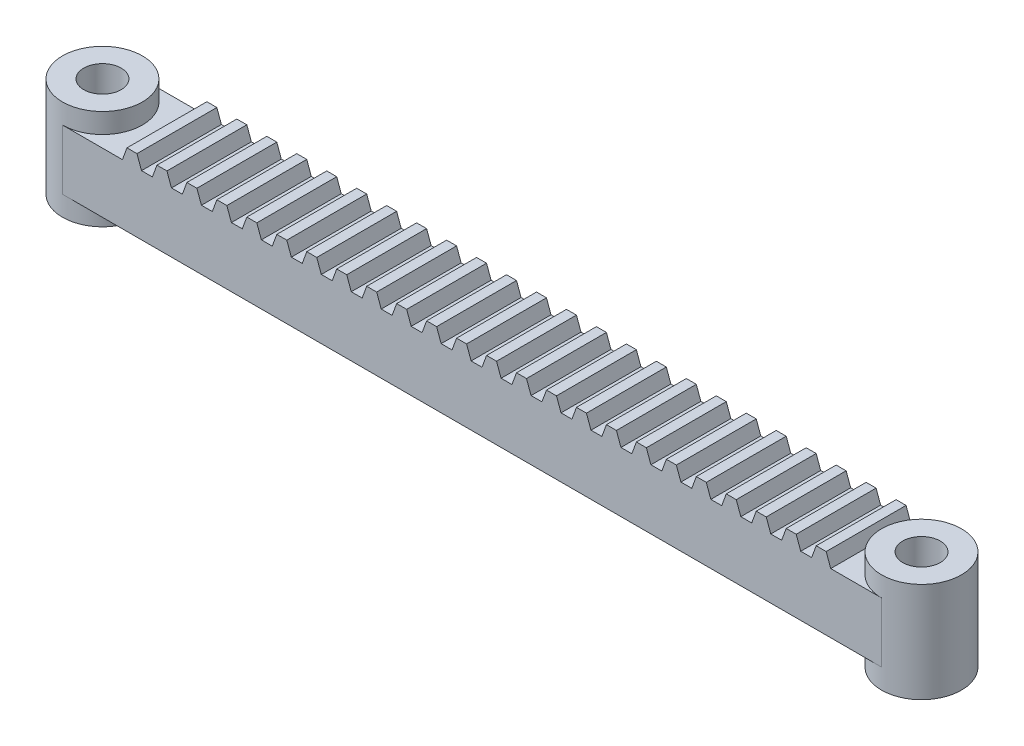
from build123d import *

# Parameters (mm, degrees)
BOSS_EXTRUDE1_DEPTH = 6
SKETCH1_3_R         = 8
SKETCH1_3_R_2       = 3.75
BOSS_EXTRUDE2_DEPTH = 10
BOSS_EXTRUDE3_DEPTH = 16


with BuildPart() as part:
    # Sketch1 → Boss-Extrude1 (new, symmetric)
    with BuildSketch(Plane(origin=(0, 0, 0), x_dir=(1, 0, 0), z_dir=(0, 1, 0))):
        with BuildLine():
            Line((82, 8), (-82, 8))
            ThreePointArc((-82, 8), (-76.343145751, 5.656854249), (-74, 0))
            ThreePointArc((-74, 0), (-76.343145751, -5.656854249), (-82, -8))
            Line((-82, -8), (82, -8))
            ThreePointArc((82, -8), (74, 0), (82, 8))
        make_face()
    extrude(amount=BOSS_EXTRUDE1_DEPTH, both=True)

    # Sketch1_3 → Boss-Extrude2 (add, symmetric)
    # profile 1 of 2: a face of its own
    with BuildSketch(Plane(origin=(0, 0, 0), x_dir=(1, 0, 0), z_dir=(0, 1, 0))):
        with Locations((-82, 0)):
            Circle(SKETCH1_3_R)
        with Locations((-82, 0)):
            Circle(SKETCH1_3_R_2, mode=Mode.SUBTRACT)
    # profile 2 of 2: a face of its own
    with BuildSketch(Plane(origin=(0, 0, 0), x_dir=(1, 0, 0), z_dir=(0, 1, 0))):
        with Locations((82, 0)):
            Circle(SKETCH1_3_R)
        with Locations((82, 0)):
            Circle(SKETCH1_3_R_2, mode=Mode.SUBTRACT)
    extrude(amount=BOSS_EXTRUDE2_DEPTH, both=True)

    # Sketch2 → Boss-Extrude3 (add)
    with BuildSketch(Plane.XY.offset(8)):
        Polygon((71.819851171, 6), (70.909925586, 8.5), (68.909925586, 8.5), (68, 6), align=None)
        Polygon((65.819851171, 6), (64.909925586, 8.5), (62.909925586, 8.5), (62, 6), align=None)
        Polygon((59.819851171, 6), (58.909925586, 8.5), (56.909925586, 8.5), (56, 6), align=None)
        Polygon((53.819851171, 6), (52.909925586, 8.5), (50.909925586, 8.5), (50, 6), align=None)
        Polygon((47.819851171, 6), (46.909925586, 8.5), (44.909925586, 8.5), (44, 6), align=None)
        Polygon((41.819851171, 6), (40.909925586, 8.5), (38.909925586, 8.5), (38, 6), align=None)
        Polygon((35.819851171, 6), (34.909925586, 8.5), (32.909925586, 8.5), (32, 6), align=None)
        Polygon((29.819851171, 6), (28.909925586, 8.5), (26.909925586, 8.5), (26, 6), align=None)
        Polygon((23.819851171, 6), (22.909925586, 8.5), (20.909925586, 8.5), (20, 6), align=None)
        Polygon((17.819851171, 6), (16.909925586, 8.5), (14.909925586, 8.5), (14, 6), align=None)
        Polygon((11.819851171, 6), (10.909925586, 8.5), (8.909925586, 8.5), (8, 6), align=None)
        Polygon((5.819851171, 6), (4.909925586, 8.5), (2.909925586, 8.5), (2, 6), align=None)
        Polygon((-0.180148829, 6), (-1.090074414, 8.5), (-3.090074414, 8.5), (-4, 6), align=None)
        Polygon((-6.180148829, 6), (-7.090074414, 8.5), (-9.090074414, 8.5), (-10, 6), align=None)
        Polygon((-12.180148829, 6), (-13.090074414, 8.5), (-15.090074414, 8.5), (-16, 6), align=None)
        Polygon((-18.180148829, 6), (-19.090074414, 8.5), (-21.090074414, 8.5), (-22, 6), align=None)
        Polygon((-24.180148829, 6), (-25.090074414, 8.5), (-27.090074414, 8.5), (-28, 6), align=None)
        Polygon((-30.180148829, 6), (-31.090074414, 8.5), (-33.090074414, 8.5), (-34, 6), align=None)
        Polygon((-36.180148829, 6), (-37.090074414, 8.5), (-39.090074414, 8.5), (-40, 6), align=None)
        Polygon((-42.180148829, 6), (-43.090074414, 8.5), (-45.090074414, 8.5), (-46, 6), align=None)
        Polygon((-48.180148829, 6), (-49.090074414, 8.5), (-51.090074414, 8.5), (-52, 6), align=None)
        Polygon((-54.180148829, 6), (-55.090074414, 8.5), (-57.090074414, 8.5), (-58, 6), align=None)
        Polygon((-60.180148829, 6), (-61.090074414, 8.5), (-63.090074414, 8.5), (-64, 6), align=None)
        Polygon((-66.180148829, 6), (-67.090074414, 8.5), (-69.090074414, 8.5), (-70, 6), align=None)
    extrude(amount=-BOSS_EXTRUDE3_DEPTH)


solid = part.part
